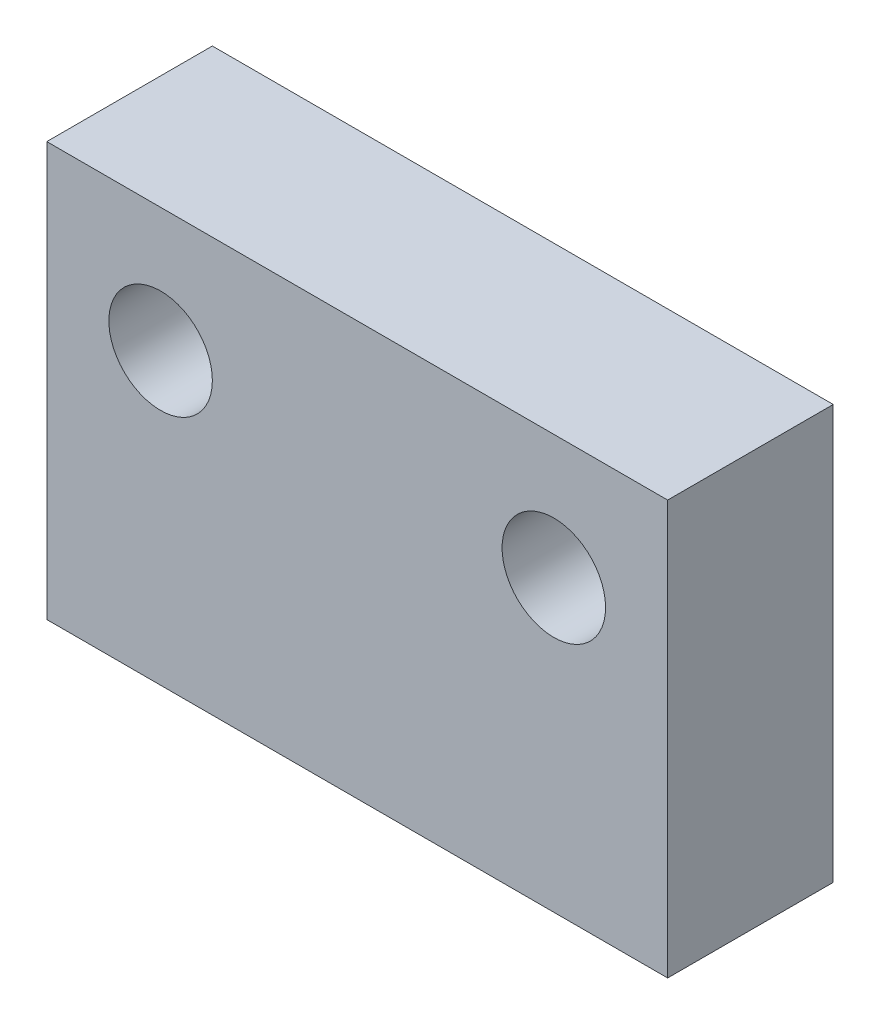
from build123d import *

# Parameters (mm, degrees)
SKETCH_1_W      = 15
SKETCH_1_H      = 10
SKETCH_1_R      = 1.25
EXTRUDE_1_DEPTH = 4


with BuildPart() as part:
    # 草图1 → 凸台-拉伸1 (new body)
    with BuildSketch(Plane.XY):
        Rectangle(SKETCH_1_W, SKETCH_1_H)
        with Locations((-4.75, 2)):
            Circle(SKETCH_1_R, mode=Mode.SUBTRACT)
        with Locations((4.75, 2)):
            Circle(SKETCH_1_R, mode=Mode.SUBTRACT)
    extrude(amount=EXTRUDE_1_DEPTH)


solid = part.part
